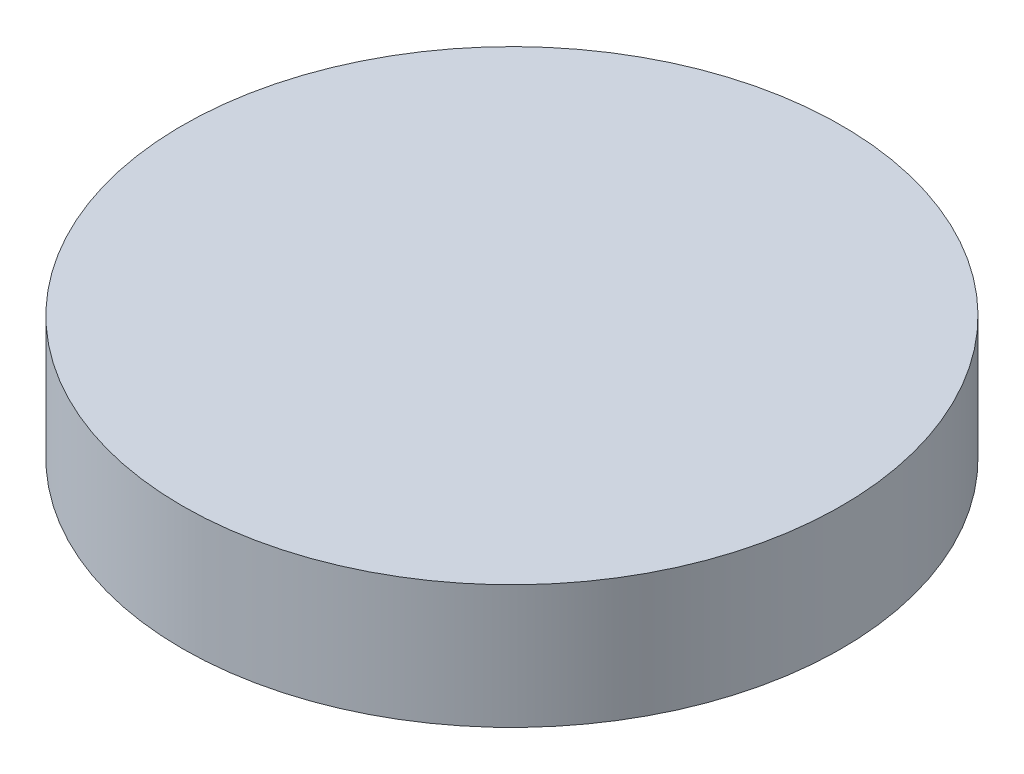
from build123d import *

# Parameters (mm, degrees)
SKETCH1_R           = 40
BOSS_EXTRUDE1_DEPTH = 15


with BuildPart() as part:
    # Sketch1 → Boss-Extrude1 (new body)
    with BuildSketch(Plane(origin=(0, 0, 0), x_dir=(1, 0, 0), z_dir=(0, 1, 0))):
        Circle(SKETCH1_R)
    extrude(amount=BOSS_EXTRUDE1_DEPTH)


solid = part.part
